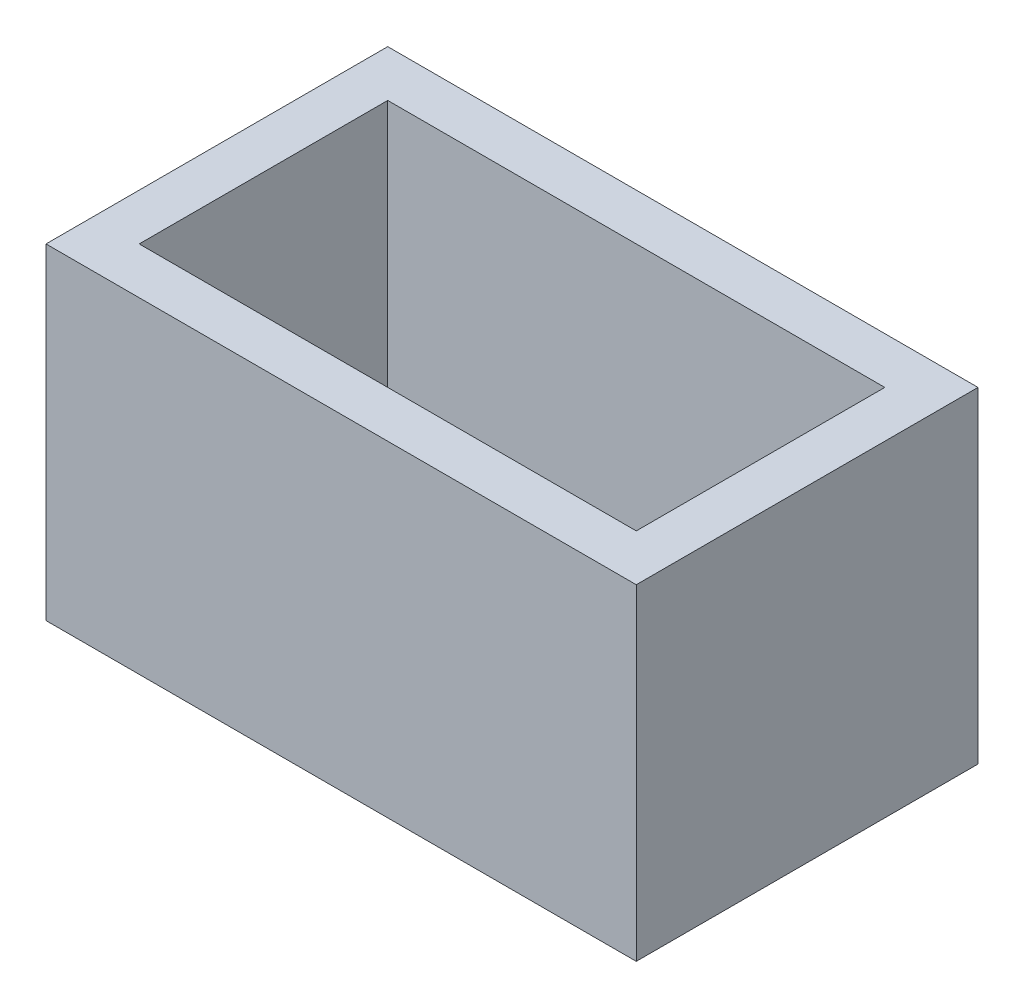
from build123d import *

# Parameters (mm, degrees)
SKETCH1_W           = 20
SKETCH1_H           = 12
BOSS_EXTRUDE1_DEPTH = 11
SHELL1_T            = -2
SKETCH3_R           = 0.625
CUT_EXTRUDE1_DEPTH  = 10
LPATTERN1_COUNT     = 2
LPATTERN1_PITCH     = 8
SKETCH5_W           = 20
SKETCH5_H           = 12
SKETCH5_W_2         = 19
SKETCH5_H_2         = 11
CUT_EXTRUDE2_DEPTH  = 12
SKETCH6_W           = 19
SKETCH6_H           = 11
CUT_EXTRUDE3_DEPTH  = 0.5


with BuildPart() as part:
    # Sketch1 → Boss-Extrude1 (new body)
    with BuildSketch(Plane(origin=(0, 0, 0), x_dir=(1, 0, 0), z_dir=(0, 1, 0))):
        with Locations((10, 6)):
            Rectangle(SKETCH1_W, SKETCH1_H)
    extrude(amount=BOSS_EXTRUDE1_DEPTH)

    # Shell1
    shell1_openings = [part.faces().sort_by_distance(p)[0] for p in [
        (10, 11, -6),
    ]]
    offset(amount=SHELL1_T, openings=shell1_openings, kind=Kind.INTERSECTION)

    # Sketch3 → Cut-Extrude1 (cut)
    with BuildSketch(Plane.XZ):
        with Locations((6, -4.73)):
            Circle(SKETCH3_R)
        with Locations((6, -7.27)):
            Circle(SKETCH3_R)
    cut_extrude1 = extrude(amount=-CUT_EXTRUDE1_DEPTH, mode=Mode.SUBTRACT)

    # LPattern1: Cut-Extrude1 ×2
    with Locations(*[(i * LPATTERN1_PITCH, 0, 0) for i in range(1, LPATTERN1_COUNT)]):
        add(cut_extrude1, mode=Mode.SUBTRACT)

    # Sketch5 → Cut-Extrude2 (cut, through all)
    with BuildSketch(Plane(origin=(0, 11, 0), x_dir=(1, 0, 0), z_dir=(0, 1, 0))):
        with Locations((10, 6)):
            Rectangle(SKETCH5_W, SKETCH5_H)
        with Locations((10, 6)):
            Rectangle(SKETCH5_W_2, SKETCH5_H_2, mode=Mode.SUBTRACT)
    extrude(amount=-CUT_EXTRUDE2_DEPTH, mode=Mode.SUBTRACT)

    # Sketch6 → Cut-Extrude3 (cut)
    with BuildSketch(Plane.XZ):
        with Locations((10, -6)):
            Rectangle(SKETCH6_W, SKETCH6_H)
    extrude(amount=-CUT_EXTRUDE3_DEPTH, mode=Mode.SUBTRACT)


solid = part.part
